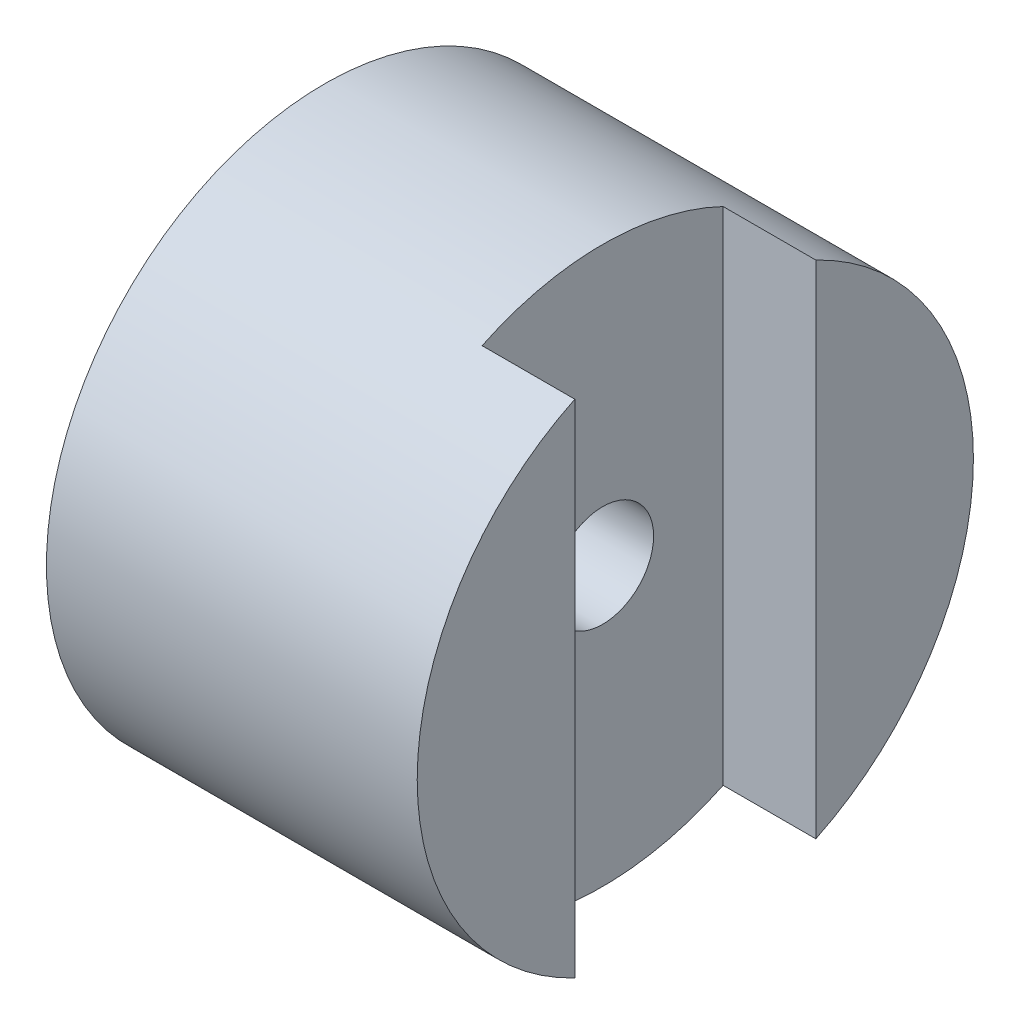
from build123d import *

# Parameters (mm, degrees)
SKETCH1_R                = 6
BOSS_EXTRUDE1_DEPTH      = 6
BOSS_EXTRUDE2_DEPTH      = 2
M2_CLEARANCE_HOLE1_D     = 2.2
M2_CLEARANCE_HOLE1_DEPTH = 6


with BuildPart() as part:
    # Sketch1 → Boss-Extrude1 (new body)
    with BuildSketch(Plane(origin=(0, 0, 0), x_dir=(0, 0, -1), z_dir=(1, 0, 0))):
        Circle(SKETCH1_R)
    extrude(amount=-BOSS_EXTRUDE1_DEPTH)

    # Sketch2 → Boss-Extrude2 (add)
    with BuildSketch(Plane(origin=(0, 0, 0), x_dir=(0, 0, -1), z_dir=(1, 0, 0))):
        with BuildLine():
            Line((-2.6, 5.407402334), (-2.6, -5.407402334))
            ThreePointArc((-2.6, -5.407402334), (-6, 0), (-2.6, 5.407402334))
        make_face()
        with BuildLine():
            Line((2.6, -5.407402334), (2.6, 5.407402334))
            ThreePointArc((2.6, 5.407402334), (6, 0), (2.6, -5.407402334))
        make_face()
    extrude(amount=BOSS_EXTRUDE2_DEPTH)

    # M2 Clearance Hole1
    with Locations(Plane(origin=(0, 0, 0), x_dir=(0, 0, -1), z_dir=(1, 0, 0))):
        with Locations((0, 0)):
            Hole(M2_CLEARANCE_HOLE1_D / 2, depth=M2_CLEARANCE_HOLE1_DEPTH)


solid = part.part
